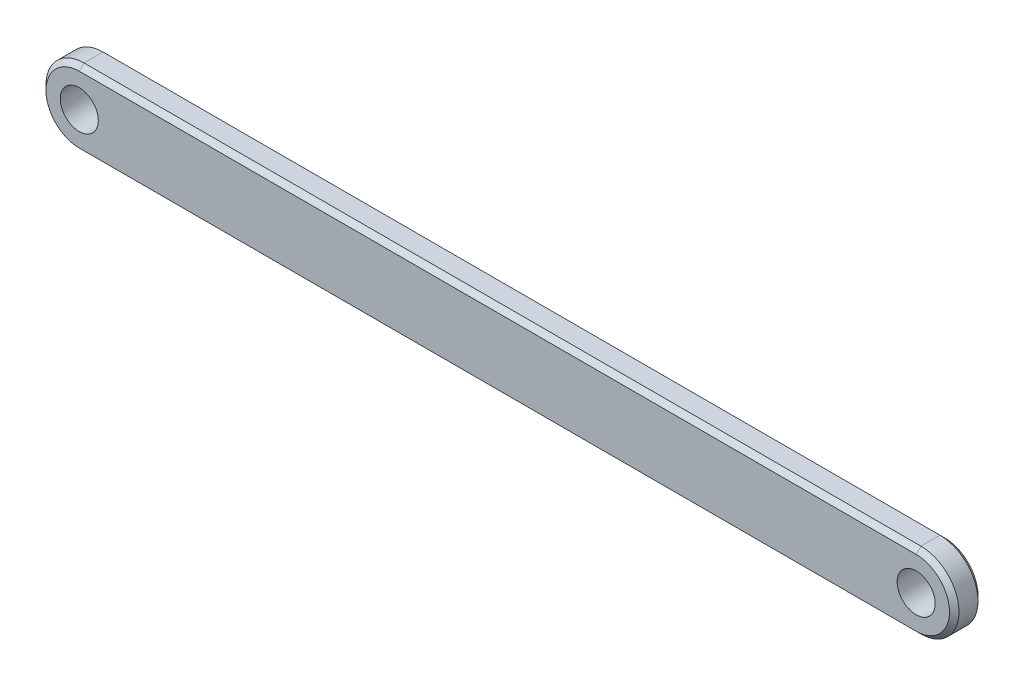
from build123d import *

# Parameters (mm, degrees)
SKETCH1_R           = 2
BOSS_EXTRUDE1_DEPTH = 1.5
CHAMFER1_SIZE       = 0.5


with BuildPart() as part:
    # Sketch1 → Boss-Extrude1 (new body, symmetric)
    with BuildSketch(Plane.XY):
        with BuildLine():
            Line((-44, 4), (44, 4))
            ThreePointArc((44, 4), (48, 0), (44, -4))
            Line((44, -4), (-44, -4))
            ThreePointArc((-44, -4), (-48, 0), (-44, 4))
        make_face()
        with Locations((-44, 0)):
            Circle(SKETCH1_R, mode=Mode.SUBTRACT)
        with Locations((44, 0)):
            Circle(SKETCH1_R, mode=Mode.SUBTRACT)
    extrude(amount=BOSS_EXTRUDE1_DEPTH, both=True)

    # Chamfer1
    chamfer1_edges = [part.edges().sort_by_distance(p)[0] for p in [
        (48, 0, 1.5),
        (0, 4, 1.5),
        (-48, 0, 1.5),
        (0, 4, -1.5),
        (48, 0, -1.5),
        (0, -4, -1.5),
        (-48, 0, -1.5),
        (0, -4, 1.5),
    ]]
    chamfer(chamfer1_edges, length=CHAMFER1_SIZE)


solid = part.part
